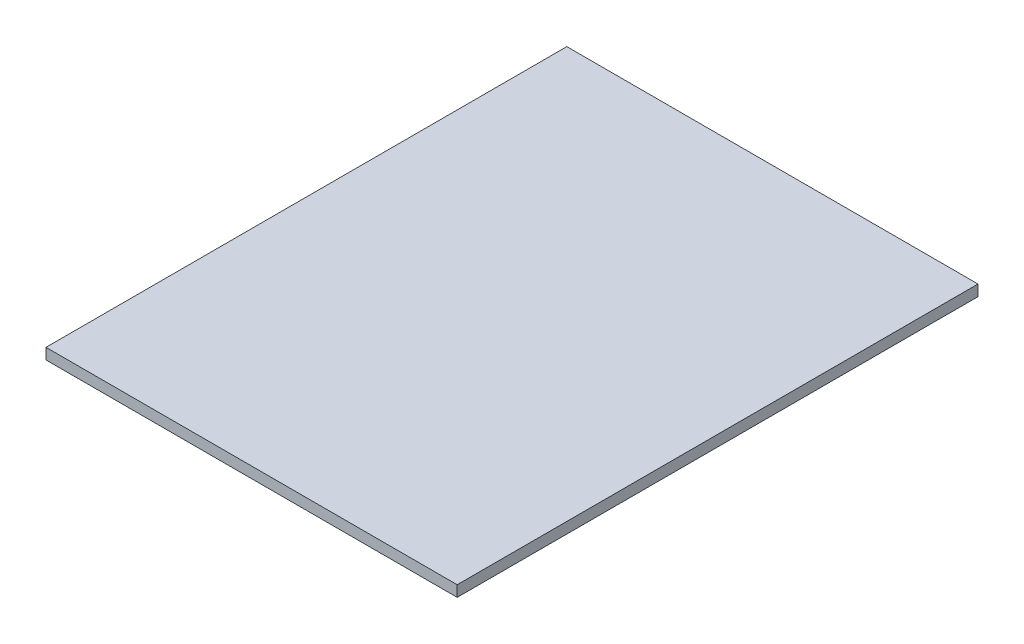
from build123d import *

# Parameters (mm, degrees)
SKETCH1_W           = 190.5
SKETCH1_H           = 241.3
BOSS_EXTRUDE1_DEPTH = 5.08


with BuildPart() as part:
    # Sketch1 → Boss-Extrude1 (new body)
    with BuildSketch(Plane(origin=(0, 0, 0), x_dir=(1, 0, 0), z_dir=(0, 1, 0))):
        Rectangle(SKETCH1_W, SKETCH1_H)
    extrude(amount=BOSS_EXTRUDE1_DEPTH)


solid = part.part
